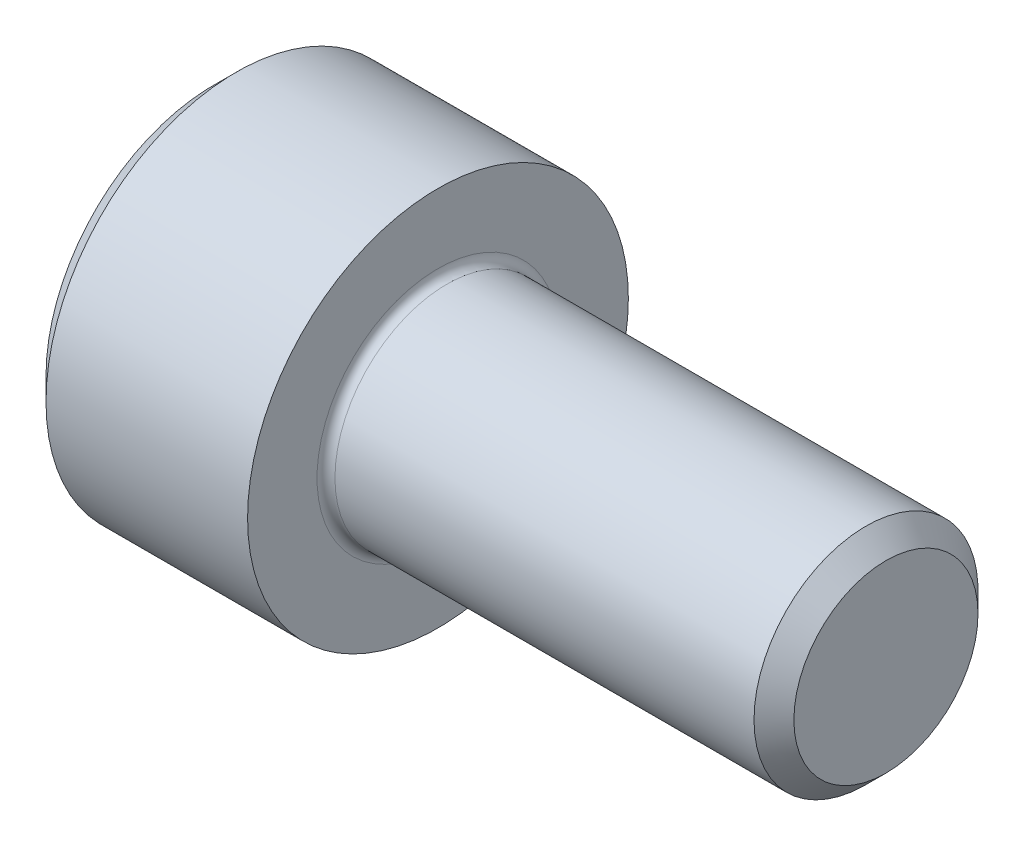
from build123d import *

# Parameters (mm, degrees)
FILLET1_R   = 0.2
HEX_2_DEPTH = 2.5


with BuildPart() as part:
    # BodySke → Base-Revolve (revolve)
    with BuildSketch(Plane.XY):
        Polygon((0, 0), (0, 3.75), (0.5, 4.25), (5, 4.25), (5, 2.5), (14.555, 2.5), (15, 2.055), (15, 0), align=None)
    revolve(axis=Axis((-31.75, 0, 0), (1, 0, 0)))

    # Fillet1
    fillet1_edges = [part.edges().sort_by_distance(p)[0] for p in [
        (5, -2.5, 0),
    ]]
    fillet(fillet1_edges, radius=FILLET1_R)

    # Sketch2 → Hex-PreBroach (revolve, cut)
    with BuildSketch(Plane.XY):
        Polygon((0, 2.042), (2.5, 2.042), (3.67894925, 0), (0, 0), align=None)
    revolve(axis=Axis((0, 0, 0), (1, 0, 0)), mode=Mode.SUBTRACT)

    # Sketch3 → Hex 2 (cut)
    with BuildSketch(Plane(origin=(0, 0, 0), x_dir=(0, 0.5, 0.866025404), z_dir=(-1, 0, 0))):
        Polygon((1.17894925, 2.042), (-1.17894925, 2.042), (-2.357898499, 0), (-1.17894925, -2.042), (1.17894925, -2.042), (2.357898499, 0), align=None)
    extrude(amount=-HEX_2_DEPTH, mode=Mode.SUBTRACT)


solid = part.part
